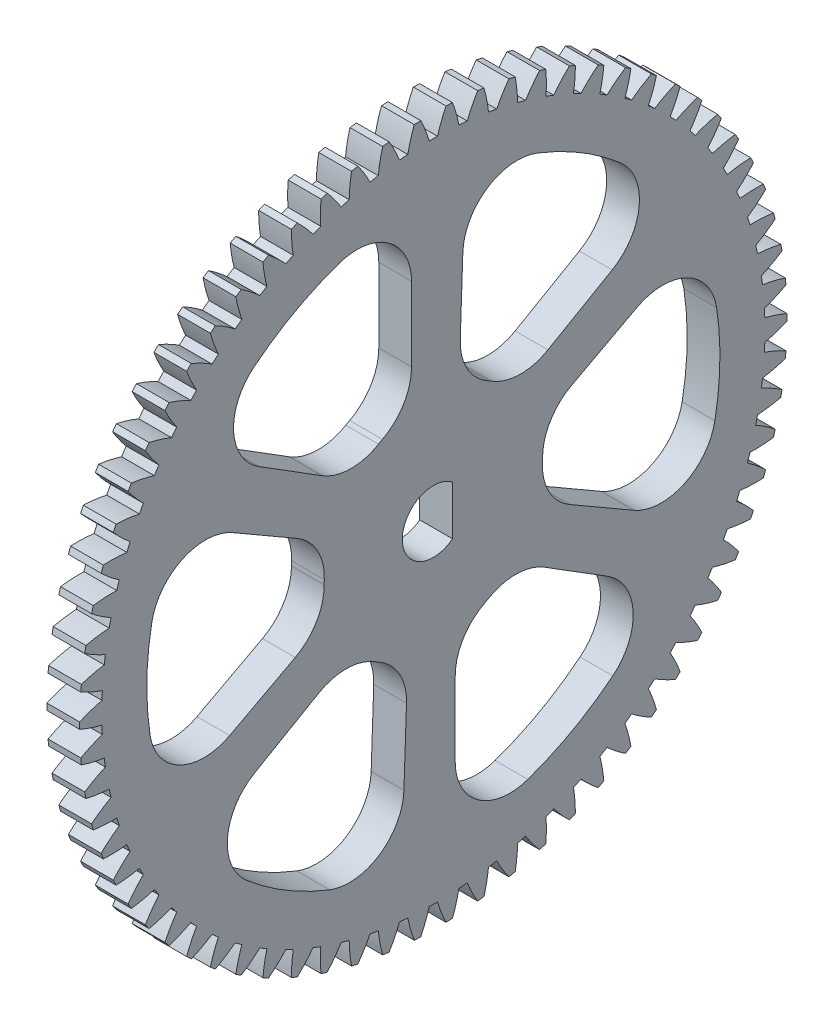
from build123d import *

# Parameters (mm, degrees)
BASPROSKE_W        = 3
BASPROSKE_H        = 32.4
TOOTHCUT_DEPTH     = 46.918623673
TEETHCUTS_COUNT    = 70
TEETHCUTS_ANGLE    = 354.857142857
CUT_EXTRUDE1_DEPTH = 46.903986576
CUT_EXTRUDE2_DEPTH = 46.903986576
CIRPATTERN3_COUNT  = 6
FILLET1_R          = 5
FILLET2_R          = 5


with BuildPart() as part:
    # BasProSke → Base-Revolve (revolve)
    with BuildSketch(Plane(origin=(0, 0, 0), x_dir=(1, 0, 0), z_dir=(0, 1, 0)), mode=Mode.PRIVATE) as base_revolve_sk:
        with Locations((1.5, 16.2)):
            Rectangle(BASPROSKE_W, BASPROSKE_H)
    revolve(base_revolve_sk.sketch.rotate(Axis((-10, 0, 0), (1, 0, 0)), 180), axis=Axis((-10, 0, 0), (1, 0, 0)))

    # TooCutSke → ToothCut (cut, through all)
    with BuildSketch(Plane(origin=(0, 0, 0), x_dir=(0, 0, -1), z_dir=(1, 0, 0))):
        with BuildLine():
            ThreePointArc((0.381861018, 30.371599533), (0, 30.374), (-0.381861018, 30.371599533))
            ThreePointArc((-0.381861018, 30.371599533), (-0.732660439, 31.405029932), (-1.171570432, 32.404227932))
            ThreePointArc((-1.171570432, 32.404227932), (0, 32.4254), (1.171570432, 32.404227932))
            ThreePointArc((1.171570432, 32.404227932), (0.732660439, 31.405029932), (0.381861018, 30.371599533))
        make_face()
    toothcut = extrude(amount=TOOTHCUT_DEPTH, mode=Mode.SUBTRACT)

    # TeethCuts: ToothCut ×70 about axis
    teethcuts_axis = Axis((-10, 0, 0), (1, 0, 0))
    for i in range(1, TEETHCUTS_COUNT):
        add(toothcut.rotate(teethcuts_axis, i * TEETHCUTS_ANGLE / (TEETHCUTS_COUNT - 1)), mode=Mode.SUBTRACT)

    # Sketch1 → Cut-Extrude1 (cut, through all)
    with BuildSketch(Plane(origin=(3, 0, 0), x_dir=(0, 0, -1), z_dir=(1, 0, 0))):
        with BuildLine():
            Line((1.749285568, 2.25), (1.749285568, -2.25))
            ThreePointArc((1.749285568, -2.25), (-2.85, 0), (1.749285568, 2.25))
        make_face()
    extrude(amount=-CUT_EXTRUDE1_DEPTH, mode=Mode.SUBTRACT)

    # Sketch2 → Cut-Extrude2 (cut, through all)
    with BuildSketch(Plane(origin=(3, 0, 0), x_dir=(0, 0, -1), z_dir=(1, 0, 0))):
        with BuildLine():
            Line((-2, 9.797958971), (-2, 26.17369863))
            ThreePointArc((-2, 26.17369863), (-12.726252531, 22.958767312), (-21.136716764, 15.566043313))
            Line((-21.136716764, 15.566043313), (-7.249301923, 6.888223401))
            ThreePointArc((-7.249301923, 6.888223401), (-4.848096202, 8.746197071), (-2, 9.797958971))
        make_face()
    cut_extrude2 = extrude(amount=-CUT_EXTRUDE2_DEPTH, mode=Mode.SUBTRACT)

    # CirPattern3: Cut-Extrude2 ×6 about axis
    cirpattern3_axis = Axis((0, 0, 0), (1, 0, 0))
    for i in range(1, CIRPATTERN3_COUNT):
        add(cut_extrude2.rotate(cirpattern3_axis, i * 360 / CIRPATTERN3_COUNT), mode=Mode.SUBTRACT)

    # Fillet1
    fillet1_edges = [part.edges().sort_by_distance(p)[0] for p in [
        (1.5, 9.797958971, 2),
        (1.5, 6.888223401, 7.249301923),
        (1.5, -6.631030293, 7.485281374),
        (1.5, -9.722191326, 2.340725491),
        (1.5, 11.354798508, 23.667087925),
        (1.5, 3.166928678, 9.485281374),
        (1.5, -2.833967925, 9.590027414),
        (1.5, -3.166928678, -9.485281374),
        (1.5, 2.833967925, -9.590027414),
        (1.5, -9.797958971, -2),
        (1.5, -6.888223401, -7.249301923),
        (1.5, 6.631030293, -7.485281374),
        (1.5, 9.722191326, -2.340725491),
    ]]
    fillet(fillet1_edges, radius=FILLET1_R)

    # Fillet2
    fillet2_edges = [part.edges().sort_by_distance(p)[0] for p in [
        (1.5, 15.566043313, 21.136716764),
        (1.5, 26.17369863, 2),
        (1.5, -26.087955327, 2.912230563),
        (1.5, -14.818900123, 21.667087925),
        (1.5, -10.521912014, 24.048947328),
        (1.5, 10.521912014, -24.048947328),
        (1.5, -11.354798508, -23.667087925),
        (1.5, -15.566043313, -21.136716764),
        (1.5, -26.17369863, -2),
        (1.5, 26.087955327, -2.912230563),
        (1.5, 14.818900123, -21.667087925),
    ]]
    fillet(fillet2_edges, radius=FILLET2_R)


solid = part.part
